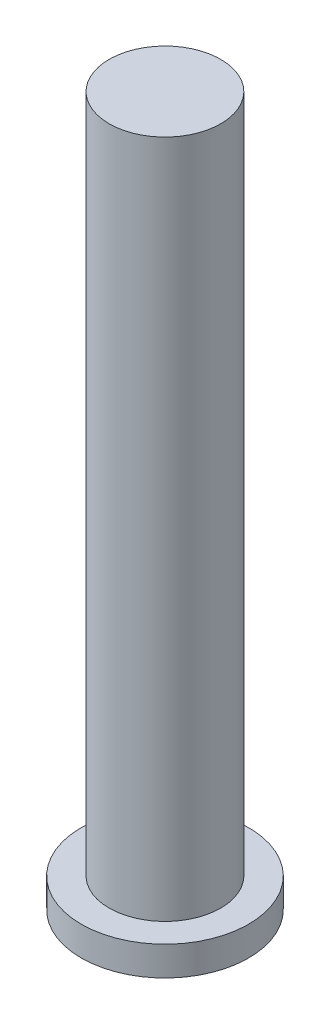
from build123d import *

# Parameters (mm, degrees)
SKETCH1_R           = 1.5
BOSS_EXTRUDE1_DEPTH = 0.525
SKETCH2_R           = 1
BOSS_EXTRUDE2_DEPTH = 12.175


with BuildPart() as part:
    # Sketch1 → Boss-Extrude1 (new body)
    with BuildSketch(Plane(origin=(0, 0, 0), x_dir=(1, 0, 0), z_dir=(0, 1, 0))):
        Circle(SKETCH1_R)
    extrude(amount=BOSS_EXTRUDE1_DEPTH)

    # Sketch2 → Boss-Extrude2 (add)
    with BuildSketch(Plane(origin=(0, 0.525, 0), x_dir=(1, 0, 0), z_dir=(0, 1, 0))):
        Circle(SKETCH2_R)
    extrude(amount=BOSS_EXTRUDE2_DEPTH)


solid = part.part
